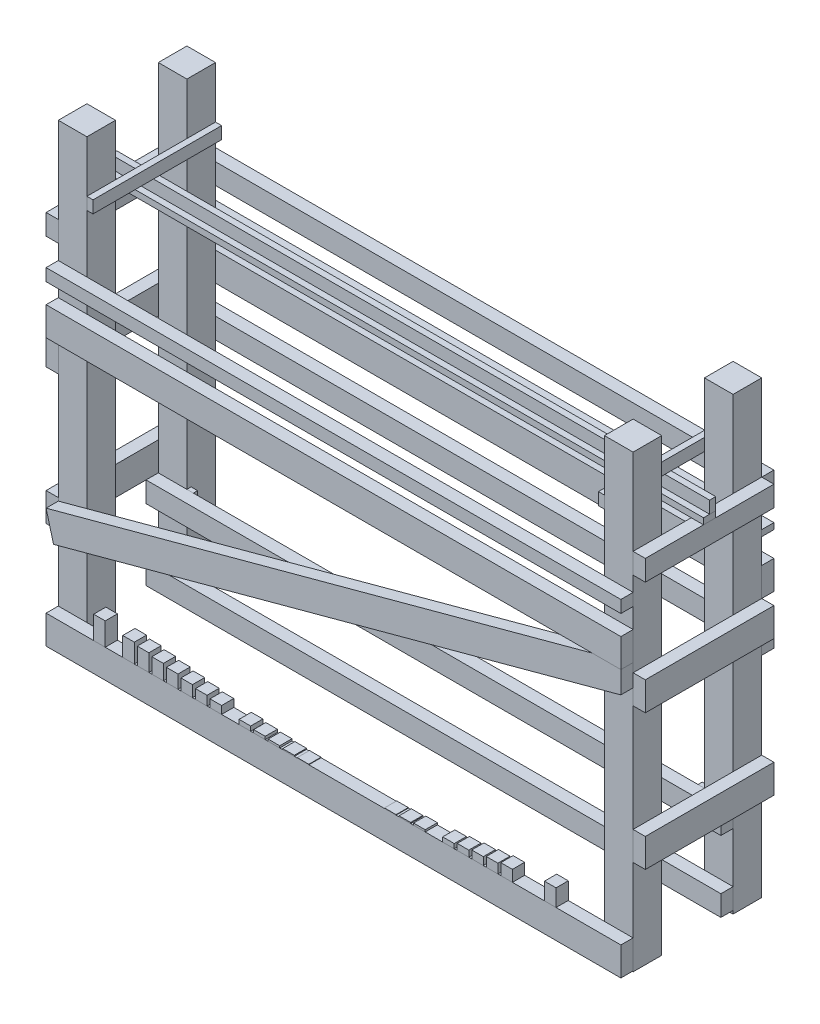
from build123d import *

# Parameters (mm, degrees)
BOSS_EXTRUDE1_DEPTH     = 38
SKETCH3_W               = 343.9
SKETCH3_H               = 9.5
BOSS_EXTRUDE2_DEPTH     = 38
SKETCH4_W               = 343.9
SKETCH4_H               = 64
SKETCH4_W_2             = 1443.9
BOSS_EXTRUDE3_DEPTH     = 38
BOSS_EXTRUDE4_DEPTH     = 38
BOSS_EXTRUDE5_DEPTH     = 38
BOSS_EXTRUDE6_DEPTH     = 89
BOSS_EXTRUDE7_DEPTH     = 89
SKETCH11_W              = 38
SKETCH11_H              = 52
SKETCH11_H_2            = 37
SKETCH11_H_3            = 38
BOSS_EXTRUDE9_DEPTH     = 1787.8
SKETCH12_W              = 89
SKETCH12_H              = 1400
BOSS_EXTRUDE10_DEPTH    = 89
BOSS_EXTRUDE10_2_DEPTH  = 89
BOSS_EXTRUDE11_DEPTH    = 38
SKETCH18_W              = 400
SKETCH18_H              = 89
BOSS_EXTRUDE12_DEPTH    = 38
BOSS_EXTRUDE12_2_DEPTH  = 38
SKETCH19_W              = 400
SKETCH19_H              = 89
BOSS_EXTRUDE13_DEPTH    = 38
BOSS_EXTRUDE13_2_DEPTH  = 38
BOSS_EXTRUDE14_DEPTH    = 38
SKETCH21_W              = 1787.8
SKETCH21_H              = 64
BOSS_EXTRUDE15_DEPTH    = 38
SKETCH26_W              = 36
SKETCH26_H              = 71
BOSS_EXTRUDE16_DEPTH    = 38
SKETCH26_H_2            = 59
BOSS_EXTRUDE16_2_DEPTH  = 38
SKETCH26_H_3            = 53
BOSS_EXTRUDE16_3_DEPTH  = 38
SKETCH26_H_4            = 47
BOSS_EXTRUDE16_4_DEPTH  = 38
SKETCH26_H_5            = 41
BOSS_EXTRUDE16_5_DEPTH  = 38
SKETCH26_H_6            = 35
BOSS_EXTRUDE16_6_DEPTH  = 38
SKETCH26_H_7            = 29
BOSS_EXTRUDE16_7_DEPTH  = 38
SKETCH26_H_8            = 24
BOSS_EXTRUDE16_8_DEPTH  = 38
SKETCH26_H_9            = 14
BOSS_EXTRUDE16_9_DEPTH  = 38
SKETCH26_H_10           = 9
BOSS_EXTRUDE16_10_DEPTH = 38
SKETCH26_H_11           = 6
BOSS_EXTRUDE16_11_DEPTH = 38
SKETCH26_H_12           = 1.5
BOSS_EXTRUDE16_12_DEPTH = 38
BOSS_EXTRUDE16_13_DEPTH = 38
SKETCH26_H_13           = 3
BOSS_EXTRUDE16_14_DEPTH = 38
BOSS_EXTRUDE16_15_DEPTH = 38
BOSS_EXTRUDE16_16_DEPTH = 38
SKETCH26_H_14           = 19
BOSS_EXTRUDE16_17_DEPTH = 38
BOSS_EXTRUDE16_18_DEPTH = 38
BOSS_EXTRUDE16_19_DEPTH = 38
BOSS_EXTRUDE16_20_DEPTH = 38
BOSS_EXTRUDE16_21_DEPTH = 38
BOSS_EXTRUDE16_22_DEPTH = 38
SKETCH27_W              = 1787.8
SKETCH27_H              = 64
BOSS_EXTRUDE20_DEPTH    = 38
BOSS_EXTRUDE20_2_DEPTH  = 38
SKETCH28_W              = 20
SKETCH28_H              = 20
BOSS_EXTRUDE21_DEPTH    = 13.3
BOSS_EXTRUDE21_2_DEPTH  = 13.3
BOSS_EXTRUDE21_3_DEPTH  = 13.3
BOSS_EXTRUDE21_4_DEPTH  = 13.3
SKETCH30_W              = 400
SKETCH30_H              = 64
BOSS_EXTRUDE22_DEPTH    = 38
SKETCH31_W              = 400
SKETCH31_H              = 64
BOSS_EXTRUDE23_DEPTH    = 38
SKETCH32_W              = 1825.8
SKETCH32_H              = 38
BOSS_EXTRUDE24_DEPTH    = 19
SKETCH33_W              = 1863.8
SKETCH33_H              = 19
BOSS_EXTRUDE25_DEPTH    = 38
BOSS_EXTRUDE26_DEPTH    = 19
SKETCH38_W              = 400
SKETCH38_H              = 38
BOSS_EXTRUDE27_DEPTH    = 19


with BuildPart() as part:
    # Sketch2 → Boss-Extrude1 (new body)
    with BuildSketch(Plane.XY):
        Polygon((1736.899943303, 918.504852866), (1647.899943303, 918.504852866), (38.099943303, 918.504852866), (-50.900056697, 918.504852866), (-50.900056697, 829.504852866), (1736.899943303, 829.504852866), align=None)
    extrude(amount=BOSS_EXTRUDE1_DEPTH)


with BuildPart() as body_2:
    # Sketch3 → Boss-Extrude2 (new body)
    with BuildSketch(Plane(origin=(0, 0, 0), x_dir=(-1, 0, 0), z_dir=(0, 0, -1))):
        Polygon((50.900056697, 1015.004852866), (-1392.999943303, 1015.004852866), (-1392.999943303, 1005.504852866), (-1392.999943303, 996.004852866), (50.900056697, 996.004852866), align=None)
        with Locations((-1564.949943303, 1010.254852866)):
            Rectangle(SKETCH3_W, SKETCH3_H)
        with Locations((-1564.949943303, 1000.754852866)):
            Rectangle(SKETCH3_W, SKETCH3_H)
    extrude(amount=-BOSS_EXTRUDE2_DEPTH)


with BuildPart() as body_3:
    # Sketch4 → Boss-Extrude3 (new body)
    with BuildSketch(Plane(origin=(0, 0, 0), x_dir=(-1, 0, 0), z_dir=(0, 0, -1))):
        with Locations((-1564.949943303, 1124.504852866)):
            Rectangle(SKETCH4_W, SKETCH4_H)
        with Locations((-671.049943303, 1124.504852866)):
            Rectangle(SKETCH4_W_2, SKETCH4_H)
    extrude(amount=-BOSS_EXTRUDE3_DEPTH)


with BuildPart() as body_4:
    # Sketch5 → Boss-Extrude4 (new body)
    with BuildSketch(Plane(origin=(0, 0, 0), x_dir=(-1, 0, 0), z_dir=(0, 0, -1))):
        Polygon((-1553.01994314, 254.526853007), (-1736.899943303, 254.526853007), (-1736.899943303, 318.526853007), (50.900056697, 318.526853007), (50.900056697, 254.526853007), align=None)
    extrude(amount=-BOSS_EXTRUDE4_DEPTH)


with BuildPart() as body_5:
    # Sketch6 → Boss-Extrude5 (new body)
    with BuildSketch(Plane(origin=(0, 0, 0), x_dir=(-1, 0, 0), z_dir=(0, 0, -1))):
        Polygon((-865.230489128, 97.849387886), (-1736.899943303, 97.849387886), (-1736.899943303, 33.849387886), (50.900056697, 33.849387886), (50.900056697, 97.849387886), align=None)
    extrude(amount=-BOSS_EXTRUDE5_DEPTH)


with BuildPart() as body_6:
    # Sketch8 → Boss-Extrude6 (new body)
    with BuildSketch(Plane.XY.offset(38)):
        Polygon((1736.899943303, 33.849387886), (1736.899943303, 23.849387886), (1647.899943303, 23.849387886), (1647.899943303, 1423.849387886), (1736.899943303, 1423.849387886), align=None)
    extrude(amount=BOSS_EXTRUDE6_DEPTH)


with BuildPart() as body_7:
    # Sketch10 → Boss-Extrude7 (new body)
    with BuildSketch(Plane.XY.offset(38)):
        Polygon((-50.900056697, 33.849387886), (-50.900056697, 23.849387886), (38.099943303, 23.849387886), (38.099943303, 1423.849387886), (-50.900056697, 1423.849387886), align=None)
    extrude(amount=BOSS_EXTRUDE7_DEPTH)


with BuildPart() as body_8:
    # Sketch11 → Boss-Extrude9 (new body, through all)
    with BuildSketch(Plane.ZY.offset(50.900056697)):
        with Locations((457, 892.504852866)):
            Rectangle(SKETCH11_W, SKETCH11_H)
        with Locations((457, 937.004852866)):
            Rectangle(SKETCH11_W, SKETCH11_H_2)
        with Locations((457, 1036.504852866)):
            Rectangle(SKETCH11_W, SKETCH11_H_3)
    extrude(amount=-BOSS_EXTRUDE9_DEPTH)


with BuildPart() as body_9:
    # Sketch12 → Boss-Extrude10 (new body)
    with BuildSketch(Plane(origin=(0, 0, 438), x_dir=(-1, 0, 0), z_dir=(0, 0, -1))):
        with Locations((-1692.399943303, 723.849387886)):
            Rectangle(SKETCH12_W, SKETCH12_H)
    extrude(amount=BOSS_EXTRUDE10_DEPTH)


with BuildPart() as body_10:
    # Sketch12 → Boss-Extrude10 2 (new body)
    with BuildSketch(Plane(origin=(0, 0, 438), x_dir=(-1, 0, 0), z_dir=(0, 0, -1))):
        with Locations((6.400056697, 723.849387886)):
            Rectangle(SKETCH12_W, SKETCH12_H)
    extrude(amount=BOSS_EXTRUDE10_2_DEPTH)


with BuildPart() as body_11:
    # Sketch16 → Boss-Extrude11 (new body)
    with BuildSketch(Plane.XY.offset(438)):
        Polygon((1736.899943303, 140.688120447), (865.230489128, 140.688120447), (-50.900056697, 140.688120447), (-50.900056697, 51.688120447), (1736.899943303, 51.688120447), align=None)
    extrude(amount=BOSS_EXTRUDE11_DEPTH)


with BuildPart() as body_12:
    # Mirror13: mirrored copy
    add(body_11.part.mirror(Plane.ZY.offset(150.900056697)))


with BuildPart() as body_13:
    # Mirror13 2: mirrored copy
    add(body_7.part.mirror(Plane.ZY.offset(150.900056697)))


with BuildPart() as body_14:
    # Mirror13 3: mirrored copy
    add(body_8.part.mirror(Plane.ZY.offset(150.900056697)))


with BuildPart() as body_15:
    # Mirror13 4: mirrored copy
    add(body_10.part.mirror(Plane.ZY.offset(150.900056697)))


with BuildPart() as body_16:
    # Mirror13 5: mirrored copy
    add(part.part.mirror(Plane.ZY.offset(150.900056697)))


with BuildPart() as body_17:
    # Mirror13 6: mirrored copy
    add(body_2.part.mirror(Plane.ZY.offset(150.900056697)))


with BuildPart() as body_18:
    # Mirror13 7: mirrored copy
    add(body_5.part.mirror(Plane.ZY.offset(150.900056697)))


with BuildPart() as body_19:
    # Mirror13 8: mirrored copy
    add(body_6.part.mirror(Plane.ZY.offset(150.900056697)))


with BuildPart() as body_20:
    # Mirror13 9: mirrored copy
    add(body_4.part.mirror(Plane.ZY.offset(150.900056697)))


with BuildPart() as body_21:
    # Mirror13 10: mirrored copy
    add(body_3.part.mirror(Plane.ZY.offset(150.900056697)))


with BuildPart() as body_22:
    # Mirror13 11: mirrored copy
    add(body_9.part.mirror(Plane.ZY.offset(150.900056697)))


with BuildPart() as body_12_2:
    # Sketch18 → Boss-Extrude12 (new body)
    with BuildSketch(Plane(origin=(-250.900056697, 0, 0), x_dir=(0, 0, -1), z_dir=(1, 0, 0))):
        with Locations((-238, 363.026853007)):
            Rectangle(SKETCH18_W, SKETCH18_H)
    extrude(amount=BOSS_EXTRUDE12_DEPTH)


with BuildPart() as body_13_2:
    # Sketch18 → Boss-Extrude12 2 (new body)
    with BuildSketch(Plane(origin=(-250.900056697, 0, 0), x_dir=(0, 0, -1), z_dir=(1, 0, 0))):
        with Locations((-238, 785.004852866)):
            Rectangle(SKETCH18_W, SKETCH18_H)
    extrude(amount=BOSS_EXTRUDE12_2_DEPTH)


with BuildPart() as body_14_2:
    # Sketch19 → Boss-Extrude13 (new body)
    with BuildSketch(Plane.ZY.offset(2038.700056697)):
        with Locations((238, 363.026853007)):
            Rectangle(SKETCH19_W, SKETCH19_H)
    extrude(amount=BOSS_EXTRUDE13_DEPTH)


with BuildPart() as body_15_2:
    # Sketch19 → Boss-Extrude13 2 (new body)
    with BuildSketch(Plane.ZY.offset(2038.700056697)):
        with Locations((238, 785.004852866)):
            Rectangle(SKETCH19_W, SKETCH19_H)
    extrude(amount=BOSS_EXTRUDE13_2_DEPTH)


with BuildPart() as body_16_2:
    # Sketch20 → Boss-Extrude14 (new body)
    with BuildSketch(Plane.XY.offset(438)):
        Polygon((-2038.700056697, 407.526853007), (-339.900056697, 866.504852866), (-250.900056697, 866.504852866), (-250.900056697, 798.359560382), (-2015.486559893, 321.607509631), align=None)
    extrude(amount=BOSS_EXTRUDE14_DEPTH)


with BuildPart() as body_17_2:
    # Sketch21 → Boss-Extrude15 (new body)
    with BuildSketch(Plane(origin=(0, 0, 38), x_dir=(-1, 0, 0), z_dir=(0, 0, -1))):
        with Locations((1144.800056697, 708.504852866)):
            Rectangle(SKETCH21_W, SKETCH21_H)
    extrude(amount=BOSS_EXTRUDE15_DEPTH)


with BuildPart() as body_14_1:
    # Body-Move/Copy1: moved
    add(body_14.part.moved(Location((0, -9.525, 0))))


with BuildPart() as body_12_1:
    # Body-Move/Copy2: moved
    add(body_12.part.moved(Location((0, -25.4, 0))))


with BuildPart() as body_18_2:
    # Sketch26 → Boss-Extrude16 (new body)
    with BuildSketch(Plane(origin=(0, 0, 438), x_dir=(-1, 0, 0), z_dir=(0, 0, -1))):
        with Locations((1872.820056534, 150.788120447)):
            Rectangle(SKETCH26_W, SKETCH26_H)
    extrude(amount=-BOSS_EXTRUDE16_DEPTH)


with BuildPart() as body_19_2:
    # Sketch26 → Boss-Extrude16 2 (new body)
    with BuildSketch(Plane(origin=(0, 0, 438), x_dir=(-1, 0, 0), z_dir=(0, 0, -1))):
        with Locations((1782.259360953, 144.788120447)):
            Rectangle(SKETCH26_W, SKETCH26_H_2)
    extrude(amount=-BOSS_EXTRUDE16_2_DEPTH)


with BuildPart() as body_20_2:
    # Sketch26 → Boss-Extrude16 3 (new body)
    with BuildSketch(Plane(origin=(0, 0, 438), x_dir=(-1, 0, 0), z_dir=(0, 0, -1))):
        with Locations((1737.029500316, 141.788120447)):
            Rectangle(SKETCH26_W, SKETCH26_H_3)
    extrude(amount=-BOSS_EXTRUDE16_3_DEPTH)


with BuildPart() as body_21_2:
    # Sketch26 → Boss-Extrude16 4 (new body)
    with BuildSketch(Plane(origin=(0, 0, 438), x_dir=(-1, 0, 0), z_dir=(0, 0, -1))):
        with Locations((1691.800809282, 138.788120447)):
            Rectangle(SKETCH26_W, SKETCH26_H_4)
    extrude(amount=-BOSS_EXTRUDE16_4_DEPTH)


with BuildPart() as body_22_2:
    # Sketch26 → Boss-Extrude16 5 (new body)
    with BuildSketch(Plane(origin=(0, 0, 438), x_dir=(-1, 0, 0), z_dir=(0, 0, -1))):
        with Locations((1646.568416649, 135.788120447)):
            Rectangle(SKETCH26_W, SKETCH26_H_5)
    extrude(amount=-BOSS_EXTRUDE16_5_DEPTH)


with BuildPart() as body_23:
    # Sketch26 → Boss-Extrude16 6 (new body)
    with BuildSketch(Plane(origin=(0, 0, 438), x_dir=(-1, 0, 0), z_dir=(0, 0, -1))):
        with Locations((1601.338509772, 132.788120447)):
            Rectangle(SKETCH26_W, SKETCH26_H_6)
    extrude(amount=-BOSS_EXTRUDE16_6_DEPTH)


with BuildPart() as body_24:
    # Sketch26 → Boss-Extrude16 7 (new body)
    with BuildSketch(Plane(origin=(0, 0, 438), x_dir=(-1, 0, 0), z_dir=(0, 0, -1))):
        with Locations((1556.106253866, 129.788120447)):
            Rectangle(SKETCH26_W, SKETCH26_H_7)
    extrude(amount=-BOSS_EXTRUDE16_7_DEPTH)


with BuildPart() as body_25:
    # Sketch26 → Boss-Extrude16 8 (new body)
    with BuildSketch(Plane(origin=(0, 0, 438), x_dir=(-1, 0, 0), z_dir=(0, 0, -1))):
        with Locations((1510.877816204, 127.288120447)):
            Rectangle(SKETCH26_W, SKETCH26_H_8)
    extrude(amount=-BOSS_EXTRUDE16_8_DEPTH)


with BuildPart() as body_26:
    # Sketch26 → Boss-Extrude16 9 (new body)
    with BuildSketch(Plane(origin=(0, 0, 438), x_dir=(-1, 0, 0), z_dir=(0, 0, -1))):
        with Locations((1420.418691907, 122.288120447)):
            Rectangle(SKETCH26_W, SKETCH26_H_9)
    extrude(amount=-BOSS_EXTRUDE16_9_DEPTH)


with BuildPart() as body_27:
    # Sketch26 → Boss-Extrude16 10 (new body)
    with BuildSketch(Plane(origin=(0, 0, 438), x_dir=(-1, 0, 0), z_dir=(0, 0, -1))):
        with Locations((1375.183958221, 119.788120447)):
            Rectangle(SKETCH26_W, SKETCH26_H_10)
    extrude(amount=-BOSS_EXTRUDE16_10_DEPTH)


with BuildPart() as body_28:
    # Sketch26 → Boss-Extrude16 11 (new body)
    with BuildSketch(Plane(origin=(0, 0, 438), x_dir=(-1, 0, 0), z_dir=(0, 0, -1))):
        with Locations((1329.955800257, 118.288120447)):
            Rectangle(SKETCH26_W, SKETCH26_H_11)
    extrude(amount=-BOSS_EXTRUDE16_11_DEPTH)


with BuildPart() as body_29:
    # Sketch26 → Boss-Extrude16 12 (new body)
    with BuildSketch(Plane(origin=(0, 0, 438), x_dir=(-1, 0, 0), z_dir=(0, 0, -1))):
        with Locations((1239.494817428, 116.038120447)):
            Rectangle(SKETCH26_W, SKETCH26_H_12)
    extrude(amount=-BOSS_EXTRUDE16_12_DEPTH)


with BuildPart() as body_30:
    # Sketch26 → Boss-Extrude16 13 (new body)
    with BuildSketch(Plane(origin=(0, 0, 438), x_dir=(-1, 0, 0), z_dir=(0, 0, -1))):
        with Locations((968.110134745, 116.038120447)):
            Rectangle(SKETCH26_W, SKETCH26_H_12)
    extrude(amount=-BOSS_EXTRUDE16_13_DEPTH)


with BuildPart() as body_31:
    # Sketch26 → Boss-Extrude16 14 (new body)
    with BuildSketch(Plane(origin=(0, 0, 438), x_dir=(-1, 0, 0), z_dir=(0, 0, -1))):
        with Locations((922.88091728, 116.788120447)):
            Rectangle(SKETCH26_W, SKETCH26_H_13)
    extrude(amount=-BOSS_EXTRUDE16_14_DEPTH)


with BuildPart() as body_32:
    # Sketch26 → Boss-Extrude16 15 (new body)
    with BuildSketch(Plane(origin=(0, 0, 438), x_dir=(-1, 0, 0), z_dir=(0, 0, -1))):
        with Locations((877.649151916, 118.288120447)):
            Rectangle(SKETCH26_W, SKETCH26_H_11)
    extrude(amount=-BOSS_EXTRUDE16_15_DEPTH)


with BuildPart() as body_33:
    # Sketch26 → Boss-Extrude16 16 (new body)
    with BuildSketch(Plane(origin=(0, 0, 438), x_dir=(-1, 0, 0), z_dir=(0, 0, -1))):
        with Locations((787.186260267, 122.288120447)):
            Rectangle(SKETCH26_W, SKETCH26_H_9)
    extrude(amount=-BOSS_EXTRUDE16_16_DEPTH)


with BuildPart() as body_34:
    # Sketch26 → Boss-Extrude16 17 (new body)
    with BuildSketch(Plane(origin=(0, 0, 438), x_dir=(-1, 0, 0), z_dir=(0, 0, -1))):
        with Locations((741.956556315, 124.788120447)):
            Rectangle(SKETCH26_W, SKETCH26_H_14)
    extrude(amount=-BOSS_EXTRUDE16_17_DEPTH)


with BuildPart() as body_35:
    # Sketch26 → Boss-Extrude16 18 (new body)
    with BuildSketch(Plane(origin=(0, 0, 438), x_dir=(-1, 0, 0), z_dir=(0, 0, -1))):
        with Locations((696.727135969, 127.288120447)):
            Rectangle(SKETCH26_W, SKETCH26_H_8)
    extrude(amount=-BOSS_EXTRUDE16_18_DEPTH)


with BuildPart() as body_36:
    # Sketch26 → Boss-Extrude16 19 (new body)
    with BuildSketch(Plane(origin=(0, 0, 438), x_dir=(-1, 0, 0), z_dir=(0, 0, -1))):
        with Locations((651.498698308, 129.788120447)):
            Rectangle(SKETCH26_W, SKETCH26_H_7)
    extrude(amount=-BOSS_EXTRUDE16_19_DEPTH)


with BuildPart() as body_37:
    # Sketch26 → Boss-Extrude16 20 (new body)
    with BuildSketch(Plane(origin=(0, 0, 438), x_dir=(-1, 0, 0), z_dir=(0, 0, -1))):
        with Locations((606.266442402, 132.788120447)):
            Rectangle(SKETCH26_W, SKETCH26_H_6)
    extrude(amount=-BOSS_EXTRUDE16_20_DEPTH)


with BuildPart() as body_38:
    # Sketch26 → Boss-Extrude16 21 (new body)
    with BuildSketch(Plane(origin=(0, 0, 438), x_dir=(-1, 0, 0), z_dir=(0, 0, -1))):
        with Locations((470.575451858, 141.788120447)):
            Rectangle(SKETCH26_W, SKETCH26_H_3)
    extrude(amount=-BOSS_EXTRUDE16_21_DEPTH)


with BuildPart() as body_39:
    # Sketch26 → Boss-Extrude16 22 (new body)
    with BuildSketch(Plane(origin=(0, 0, 438), x_dir=(-1, 0, 0), z_dir=(0, 0, -1))):
        with Locations((1284.724034894, 116.788120447)):
            Rectangle(SKETCH26_W, SKETCH26_H_13)
    extrude(amount=-BOSS_EXTRUDE16_22_DEPTH)


with BuildPart() as body_40:
    # Sketch27 → Boss-Extrude20 (new body)
    with BuildSketch(Plane.XY.offset(127)):
        with Locations((-1144.800056697, 65.849387886)):
            Rectangle(SKETCH27_W, SKETCH27_H)
    extrude(amount=BOSS_EXTRUDE20_DEPTH)


with BuildPart() as body_41:
    # Sketch27 → Boss-Extrude20 2 (new body)
    with BuildSketch(Plane.XY.offset(127)):
        with Locations((-1144.800056697, 286.526853007)):
            Rectangle(SKETCH27_W, SKETCH27_H)
    extrude(amount=BOSS_EXTRUDE20_2_DEPTH)


with BuildPart() as body_40_2:
    # Sketch28 → Boss-Extrude21 (new body)
    with BuildSketch(Plane(origin=(0, 0, 127), x_dir=(-1, 0, 0), z_dir=(0, 0, -1))):
        with Locations((349.900056697, 308.526853007)):
            Rectangle(SKETCH28_W, SKETCH28_H)
    extrude(amount=BOSS_EXTRUDE21_DEPTH)


with BuildPart() as body_41_2:
    # Sketch28 → Boss-Extrude21 2 (new body)
    with BuildSketch(Plane(origin=(0, 0, 127), x_dir=(-1, 0, 0), z_dir=(0, 0, -1))):
        with Locations((349.900056697, 43.849387886)):
            Rectangle(SKETCH28_W, SKETCH28_H)
    extrude(amount=BOSS_EXTRUDE21_2_DEPTH)


with BuildPart() as body_42:
    # Sketch28 → Boss-Extrude21 3 (new body)
    with BuildSketch(Plane(origin=(0, 0, 127), x_dir=(-1, 0, 0), z_dir=(0, 0, -1))):
        with Locations((1939.700056697, 308.526853007)):
            Rectangle(SKETCH28_W, SKETCH28_H)
    extrude(amount=BOSS_EXTRUDE21_3_DEPTH)


with BuildPart() as body_43:
    # Sketch28 → Boss-Extrude21 4 (new body)
    with BuildSketch(Plane(origin=(0, 0, 127), x_dir=(-1, 0, 0), z_dir=(0, 0, -1))):
        with Locations((1939.700056697, 43.849387886)):
            Rectangle(SKETCH28_W, SKETCH28_H)
    extrude(amount=BOSS_EXTRUDE21_4_DEPTH)


with BuildPart() as body_16_2_1:
    # Body-Move/Copy3: moved
    add(body_16_2.part.moved(Location((0, -9.525, 0))))


with BuildPart() as body_44:
    # Sketch30 → Boss-Extrude22 (new body)
    with BuildSketch(Plane(origin=(-250.900056697, 0, 0), x_dir=(0, 0, -1), z_dir=(1, 0, 0))):
        with Locations((-238, 1124.504852866)):
            Rectangle(SKETCH30_W, SKETCH30_H)
    extrude(amount=BOSS_EXTRUDE22_DEPTH)


with BuildPart() as body_45:
    # Sketch31 → Boss-Extrude23 (new body)
    with BuildSketch(Plane.ZY.offset(2038.700056697)):
        with Locations((238, 1124.504852866)):
            Rectangle(SKETCH31_W, SKETCH31_H)
    extrude(amount=BOSS_EXTRUDE23_DEPTH)


with BuildPart() as body_46:
    # Sketch32 → Boss-Extrude24 (new body)
    with BuildSketch(Plane(origin=(0, 1156.504852866, 0), x_dir=(1, 0, 0), z_dir=(0, 1, 0))):
        with Locations((-1125.800056697, -238)):
            Rectangle(SKETCH32_W, SKETCH32_H)
        Polygon((-2076.700056697, -238), (-2076.700056697, -257), (-2038.700056697, -257), (-2038.700056697, -219), (-2076.700056697, -219), align=None)
    extrude(amount=BOSS_EXTRUDE24_DEPTH)


with BuildPart() as body_47:
    # Sketch33 → Boss-Extrude25 (new body)
    with BuildSketch(Plane(origin=(0, 1175.504852866, 0), x_dir=(1, 0, 0), z_dir=(0, 1, 0))):
        with Locations((-1144.800056697, -228.5)):
            Rectangle(SKETCH33_W, SKETCH33_H)
    extrude(amount=BOSS_EXTRUDE25_DEPTH)


with BuildPart() as body_48:
    # Sketch37 → Boss-Extrude26 (new body)
    with BuildSketch(Plane.ZY.offset(339.900056697)):
        Polygon((127, 1263.504852866), (38, 1263.504852866), (38, 1225.504852866), (438, 1225.504852866), (438, 1263.504852866), align=None)
    extrude(amount=BOSS_EXTRUDE26_DEPTH)


with BuildPart() as body_49:
    # Sketch38 → Boss-Extrude27 (new body)
    with BuildSketch(Plane(origin=(-1949.700056697, 0, 0), x_dir=(0, 0, -1), z_dir=(1, 0, 0))):
        with Locations((-238, 1244.504852866)):
            Rectangle(SKETCH38_W, SKETCH38_H)
    extrude(amount=BOSS_EXTRUDE27_DEPTH)


solid = Compound([body_13.part, body_15.part, body_16.part, body_17.part, body_19.part, body_21.part, body_22.part, body_12_2.part, body_13_2.part, body_14_2.part, body_15_2.part, body_17_2.part, body_14_1.part, body_12_1.part, body_18_2.part, body_19_2.part, body_20_2.part, body_21_2.part, body_22_2.part, body_23.part, body_24.part, body_25.part, body_26.part, body_27.part, body_28.part, body_29.part, body_30.part, body_31.part, body_32.part, body_33.part, body_34.part, body_35.part, body_36.part, body_37.part, body_38.part, body_39.part, body_40.part, body_41.part, body_40_2.part, body_41_2.part, body_42.part, body_43.part, body_16_2_1.part, body_44.part, body_45.part, body_46.part, body_47.part, body_48.part, body_49.part])
